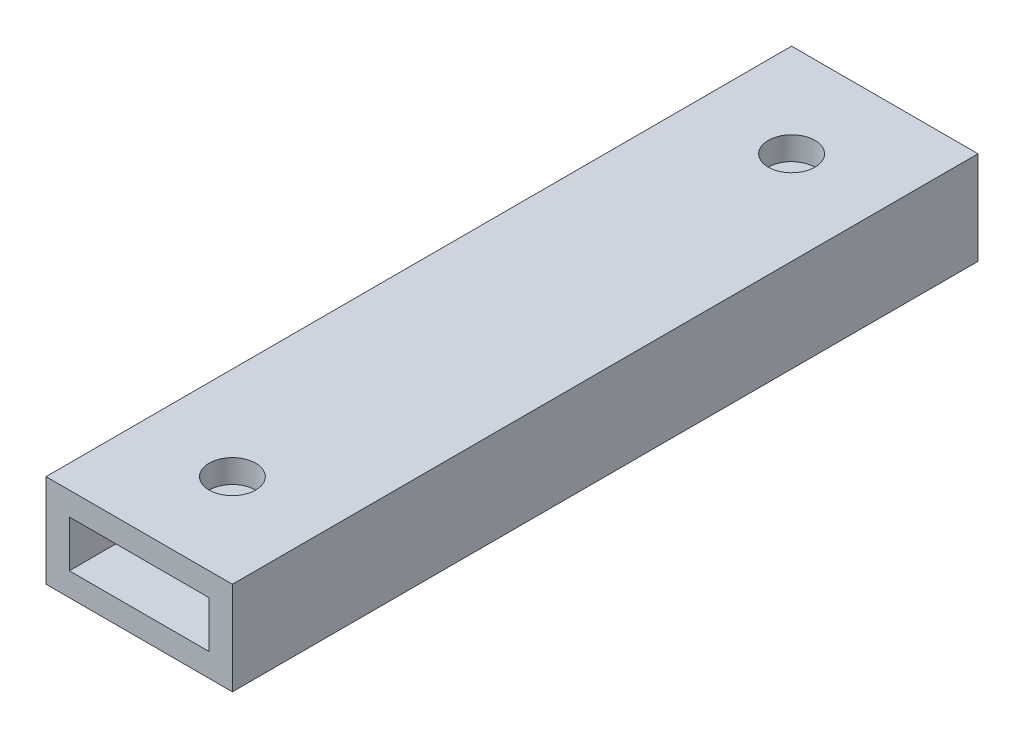
from build123d import *

# Parameters (mm, degrees)
SKETCH1_W           = 25.4
SKETCH1_H           = 12.7
SKETCH1_W_2         = 19.05
SKETCH1_H_2         = 6.35
BOSS_EXTRUDE1_DEPTH = 101.6
SKETCH2_R           = 3.175
CUT_EXTRUDE1_DEPTH  = 13.7


with BuildPart() as part:
    # Sketch1 → Boss-Extrude1 (new body)
    with BuildSketch(Plane.XY):
        with Locations((12.7, 6.35)):
            Rectangle(SKETCH1_W, SKETCH1_H)
        with Locations((12.7, 6.35)):
            Rectangle(SKETCH1_W_2, SKETCH1_H_2, mode=Mode.SUBTRACT)
    extrude(amount=BOSS_EXTRUDE1_DEPTH)

    # Sketch2 → Cut-Extrude1 (cut, through all)
    with BuildSketch(Plane(origin=(0, 12.7, 0), x_dir=(1, 0, 0), z_dir=(0, 1, 0))):
        with Locations((12.7, -88.9)):
            Circle(SKETCH2_R)
        with Locations((12.7, -12.7)):
            Circle(SKETCH2_R)
    extrude(amount=-CUT_EXTRUDE1_DEPTH, mode=Mode.SUBTRACT)


solid = part.part
